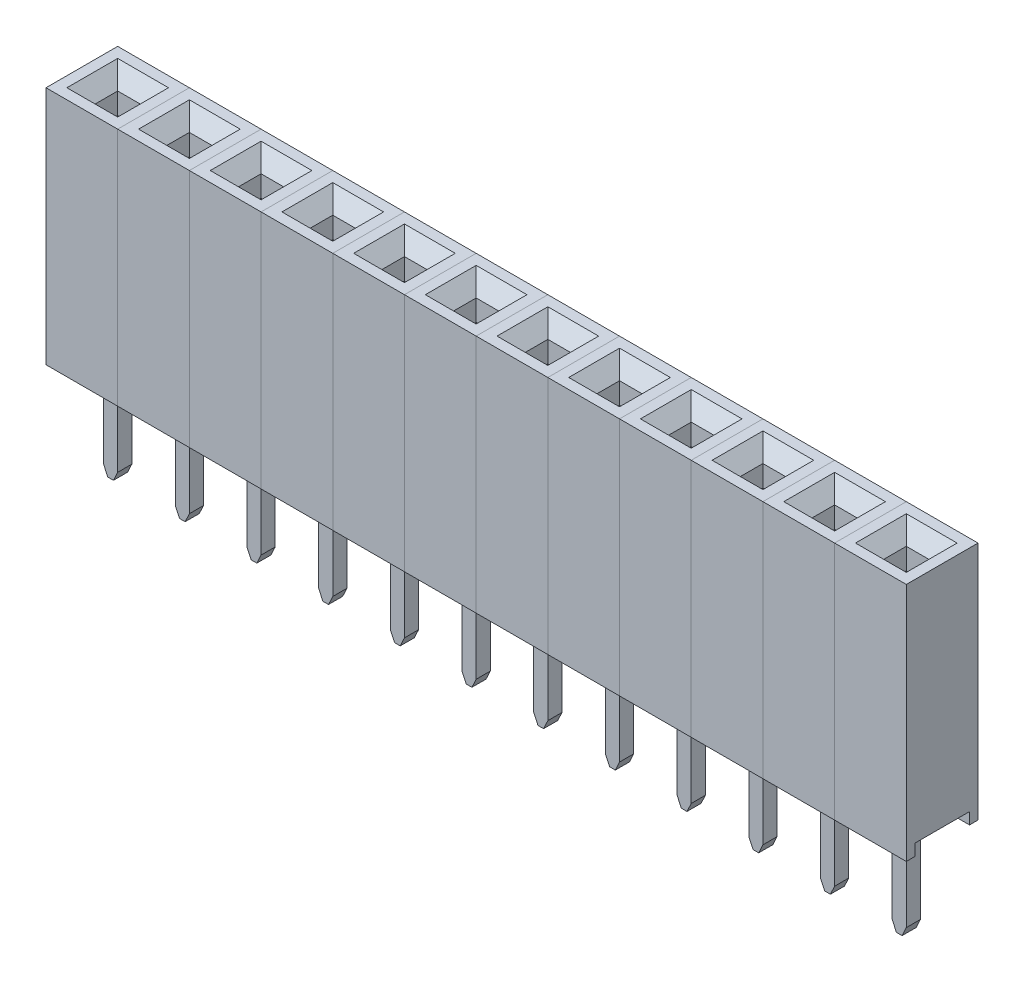
from build123d import *

# Parameters (mm, degrees)
SKETCH1_W               = 2.54
SKETCH1_H               = 8.5
BOSS_EXTRUDE1_DEPTH     = 1.27
SKETCH2_W               = 1.94
SKETCH2_H               = 0.410374384
CUT_EXTRUDE1_DEPTH      = 50
SKETCH4_W               = 0.8
SKETCH4_H               = 0.8
CUT_EXTRUDE2_DEPTH      = 1.5
CHAMFER1_SIZE           = 0.5
CUT_EXTRUDE3_DEPTH      = 3
CUT_EXTRUDE3_DEPTH_BACK = 3
SKETCH5_W               = 1.8
SKETCH5_H               = 1.8
BOSS_EXTRUDE4_DEPTH     = 0.85
BOSS_EXTRUDE5_DEPTH     = 0.25
LPATTERN1_COUNT         = 12
LPATTERN1_PITCH         = 2.54


with BuildPart() as part:
    # Sketch1 → Boss-Extrude1 (new, symmetric)
    with BuildSketch(Plane.XY):
        Rectangle(SKETCH1_W, SKETCH1_H)
    extrude(amount=BOSS_EXTRUDE1_DEPTH, both=True)

    # Sketch2 → Cut-Extrude1 (cut, symmetric)
    with BuildSketch(Plane(origin=(0, 0, 0), x_dir=(0, 0, -1), z_dir=(1, 0, 0))):
        with Locations((0, -4.044812808)):
            Rectangle(SKETCH2_W, SKETCH2_H)
    extrude(amount=CUT_EXTRUDE1_DEPTH, both=True, mode=Mode.SUBTRACT)

    # Sketch4 → Cut-Extrude2 (cut)
    with BuildSketch(Plane(origin=(0, 4.25, 0), x_dir=(1, 0, 0), z_dir=(0, 1, 0))):
        Rectangle(SKETCH4_W, SKETCH4_H)
    extrude(amount=-CUT_EXTRUDE2_DEPTH, mode=Mode.SUBTRACT)

    # Chamfer1
    chamfer1_edges = [part.edges().sort_by_distance(p)[0] for p in [
        (0, 4.25, -0.4),
        (-0.4, 4.25, 0),
        (0, 4.25, 0.4),
        (0.4, 4.25, 0),
    ]]
    chamfer(chamfer1_edges, length=CHAMFER1_SIZE)

    # Sketch5 → Cut-Extrude3 (cut, two sides: drawn at the far end of the back side and taken through both)
    with BuildSketch(Plane(origin=(0, 0, 0), x_dir=(1, 0, 0), z_dir=(0, 1, 0)).offset(-CUT_EXTRUDE3_DEPTH_BACK)):
        Rectangle(SKETCH5_W, SKETCH5_H)
    extrude(amount=CUT_EXTRUDE3_DEPTH + CUT_EXTRUDE3_DEPTH_BACK, mode=Mode.SUBTRACT)

    # Sketch9 → Boss-Extrude4 (add, symmetric)
    with BuildSketch(Plane.XY):
        with BuildLine():
            Line((0.852765845, -2.693306042), (0.852765845, -1.341648528))
            Line((0.852765845, -1.341648528), (0.602186386, -1.260876719))
            Line((0.602186386, -1.260876719), (0.413271806, 1.491878581))
            ThreePointArc((0.413271806, 1.491878581), (0.162585139, 1.576117793), (0.280281264, 1.339289432))
            Line((0.280281264, 1.339289432), (0.507505583, -1.97169351))
            ThreePointArc((0.507505583, -1.97169351), (0.361743925, -2.312679398), (0, -2.394283131))
            ThreePointArc((0, -2.394283131), (-0.361743925, -2.312679398), (-0.507505583, -1.97169351))
            Line((-0.507505583, -1.97169351), (-0.280281264, 1.339289432))
            ThreePointArc((-0.280281264, 1.339289432), (-0.162585139, 1.576117793), (-0.413271806, 1.491878581))
            Line((-0.413271806, 1.491878581), (-0.602186386, -1.260876719))
            Line((-0.602186386, -1.260876719), (-0.852765845, -1.341648528))
            Line((-0.852765845, -1.341648528), (-0.852765845, -2.693306042))
            Line((-0.852765845, -2.693306042), (-0.280728289, -3.053320584))
            Line((-0.280728289, -3.053320584), (-0.25, -3.053320584))
            Line((-0.25, -3.053320584), (0.25, -3.053320584))
            Line((0.25, -3.053320584), (0.280728289, -3.053320584))
            Line((0.280728289, -3.053320584), (0.852765845, -2.693306042))
        make_face()
    extrude(amount=BOSS_EXTRUDE4_DEPTH, both=True)

    # Sketch9_3 → Boss-Extrude5 (add, symmetric)
    with BuildSketch(Plane.XY):
        Polygon((0.25, -7.299491593), (0.25, -3.053320584), (-0.25, -3.053320584), (-0.25, -7.299491593), (-0.1, -7.621167632), (0.1, -7.621167632), align=None)
    extrude(amount=BOSS_EXTRUDE5_DEPTH, both=True)


with BuildPart() as lpattern1_1:
    # LPattern1: pattern copy
    add(part.part.moved(Location(Vector(-1, 0, 0) * (1 * LPATTERN1_PITCH))))


with BuildPart() as lpattern1_2:
    # LPattern1: pattern copy
    add(part.part.moved(Location(Vector(-1, 0, 0) * (2 * LPATTERN1_PITCH))))


with BuildPart() as lpattern1_3:
    # LPattern1: pattern copy
    add(part.part.moved(Location(Vector(-1, 0, 0) * (3 * LPATTERN1_PITCH))))


with BuildPart() as lpattern1_4:
    # LPattern1: pattern copy
    add(part.part.moved(Location(Vector(-1, 0, 0) * (4 * LPATTERN1_PITCH))))


with BuildPart() as lpattern1_5:
    # LPattern1: pattern copy
    add(part.part.moved(Location(Vector(-1, 0, 0) * (5 * LPATTERN1_PITCH))))


with BuildPart() as lpattern1_6:
    # LPattern1: pattern copy
    add(part.part.moved(Location(Vector(-1, 0, 0) * (6 * LPATTERN1_PITCH))))


with BuildPart() as lpattern1_7:
    # LPattern1: pattern copy
    add(part.part.moved(Location(Vector(-1, 0, 0) * (7 * LPATTERN1_PITCH))))


with BuildPart() as lpattern1_8:
    # LPattern1: pattern copy
    add(part.part.moved(Location(Vector(-1, 0, 0) * (8 * LPATTERN1_PITCH))))


with BuildPart() as lpattern1_9:
    # LPattern1: pattern copy
    add(part.part.moved(Location(Vector(-1, 0, 0) * (9 * LPATTERN1_PITCH))))


with BuildPart() as lpattern1_10:
    # LPattern1: pattern copy
    add(part.part.moved(Location(Vector(-1, 0, 0) * (10 * LPATTERN1_PITCH))))


with BuildPart() as lpattern1_11:
    # LPattern1: pattern copy
    add(part.part.moved(Location(Vector(-1, 0, 0) * (11 * LPATTERN1_PITCH))))


solid = Compound([part.part, lpattern1_1.part, lpattern1_2.part, lpattern1_3.part, lpattern1_4.part, lpattern1_5.part, lpattern1_6.part, lpattern1_7.part, lpattern1_8.part, lpattern1_9.part, lpattern1_10.part, lpattern1_11.part])
